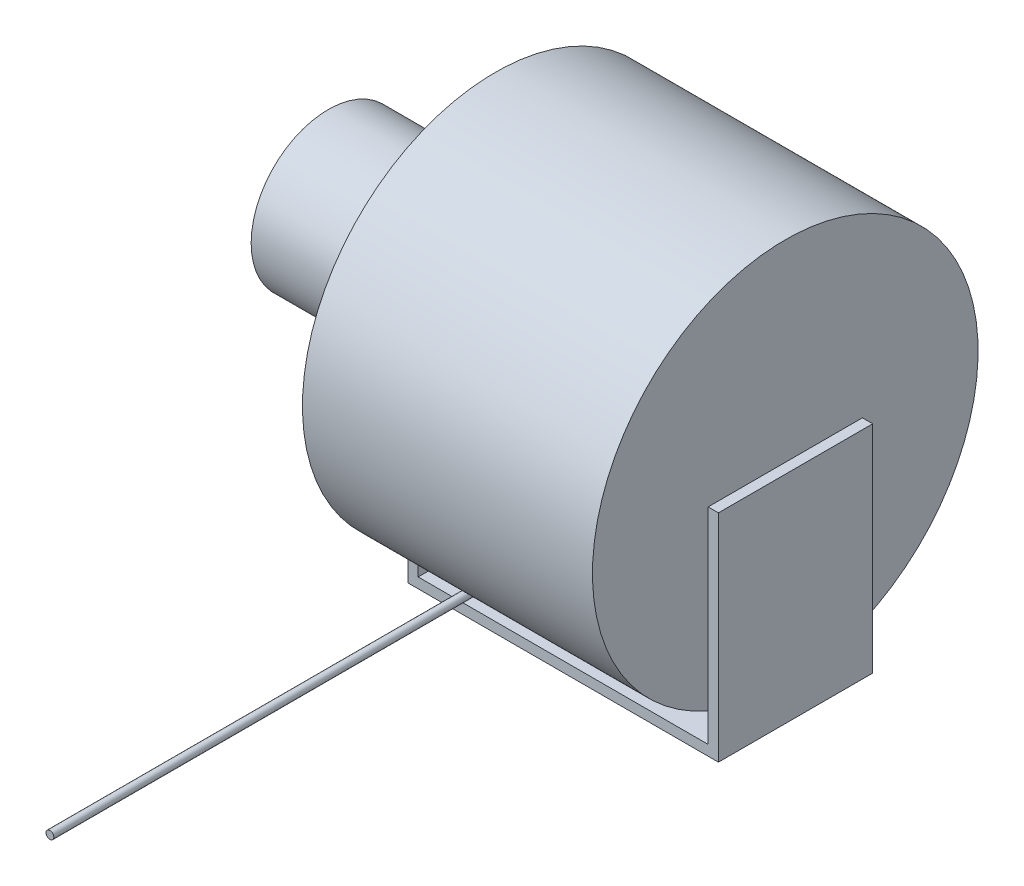
from build123d import *

# Parameters (mm, degrees)
SKETCH1_R           = 187.5
BOSS_EXTRUDE1_DEPTH = 282
SKETCH2_W           = 150
SKETCH2_H           = 210
BOSS_EXTRUDE2_DEPTH = 10
SKETCH3_W           = 150
SKETCH3_H           = 210
BOSS_EXTRUDE3_DEPTH = 10
BOSS_EXTRUDE4_REACH = 294
SKETCH4_W           = 150
SKETCH4_H           = 10
SKETCH5_R           = 75
BOSS_EXTRUDE5_DEPTH = 152.4
SKETCH8_R           = 3.8
SKETCH9_R           = 3.8
BOSS_EXTRUDE6_DEPTH = 283.8


with BuildPart() as part:
    # Sketch1 → Boss-Extrude1 (new body)
    with BuildSketch(Plane(origin=(0, 0, 0), x_dir=(0, 0, -1), z_dir=(1, 0, 0))):
        Circle(SKETCH1_R)
    extrude(amount=BOSS_EXTRUDE1_DEPTH)

    # Sketch2 → Boss-Extrude2 (add)
    with BuildSketch(Plane.ZY):
        with Locations((0, -105)):
            Rectangle(SKETCH2_W, SKETCH2_H)
    extrude(amount=BOSS_EXTRUDE2_DEPTH)

    # Sketch3 → Boss-Extrude3 (add)
    with BuildSketch(Plane(origin=(282, 0, 0), x_dir=(0, 0, -1), z_dir=(1, 0, 0))):
        with Locations((0, -105)):
            Rectangle(SKETCH3_W, SKETCH3_H)
    extrude(amount=BOSS_EXTRUDE3_DEPTH)

    # Sketch4 → Boss-Extrude4 (add, up to next)
    with BuildSketch(Plane(origin=(0, 0, 0), x_dir=(0, 0, -1), z_dir=(1, 0, 0)), mode=Mode.PRIVATE) as boss_extrude4_sk1:
        with Locations((0, -205)):
            Rectangle(SKETCH4_W, SKETCH4_H)
    boss_extrude4_tool1 = extrude(boss_extrude4_sk1.sketch, amount=BOSS_EXTRUDE4_REACH, mode=Mode.PRIVATE) - part.part
    add(boss_extrude4_tool1.solids().sort_by_distance((0, -205, 0))[0])

    # Sketch5 → Boss-Extrude5 (add)
    with BuildSketch(Plane.ZY.offset(10)):
        Circle(SKETCH5_R)
    extrude(amount=BOSS_EXTRUDE5_DEPTH)

    # Sweep2: sweep along a path in Sketch6
    with BuildLine(Plane(origin=(50.7, 0, 0), x_dir=(0, 0, -1), z_dir=(1, 0, 0))) as sweep2_path:
        Line((0, -187.5), (-200, -187.5))
    # Sketch8 → Sweep2 (sweep)
    with BuildSketch(Plane.XY.offset(200)):
        with Locations((50.7, -187.5)):
            Circle(SKETCH8_R)
    sweep(path=sweep2_path.line)

    # Sketch9 → Boss-Extrude6 (add)
    with BuildSketch(Plane.XY.offset(200)):
        with Locations((50.7, -187.5)):
            Circle(SKETCH9_R)
    extrude(amount=BOSS_EXTRUDE6_DEPTH)


solid = part.part
